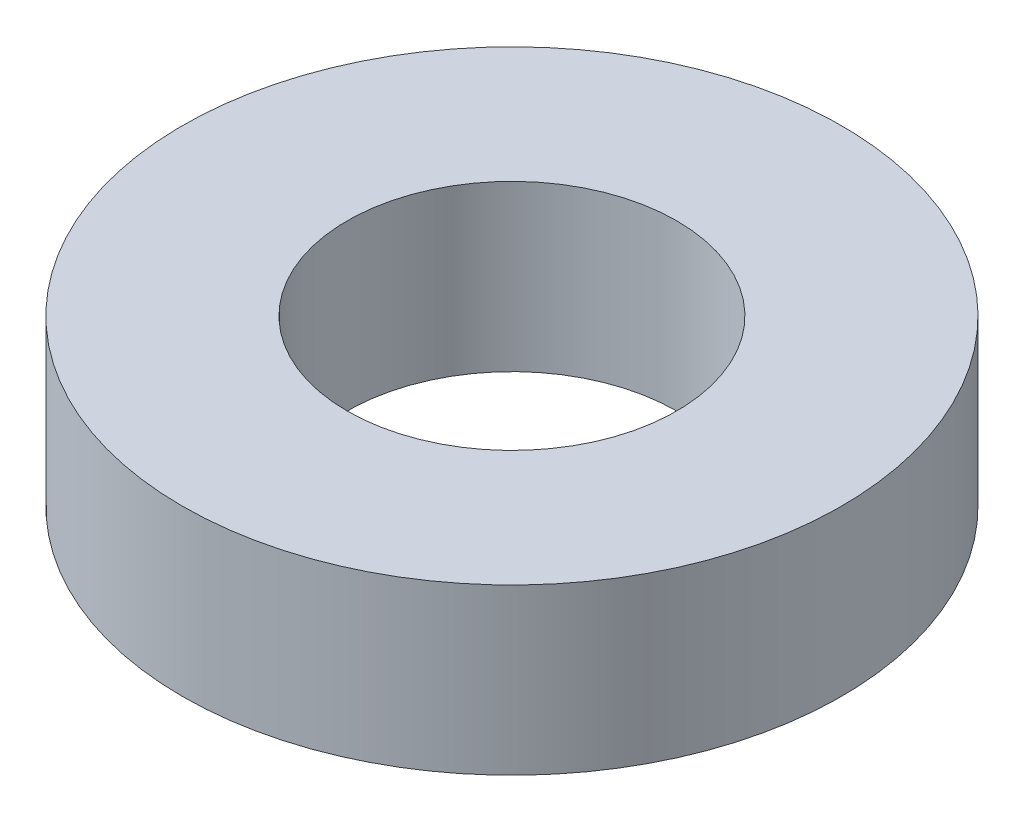
from build123d import *

# Parameters (mm, degrees)
SKETCH1_R           = 6.35
SKETCH1_R_2         = 3.175
BOSS_EXTRUDE2_DEPTH = 3.175


with BuildPart() as part:
    # Sketch1 → Boss-Extrude2 (new body)
    with BuildSketch(Plane(origin=(0, 0, 0), x_dir=(1, 0, 0), z_dir=(0, 1, 0))):
        Circle(SKETCH1_R)
        Circle(SKETCH1_R_2, mode=Mode.SUBTRACT)
    extrude(amount=BOSS_EXTRUDE2_DEPTH)


solid = part.part
